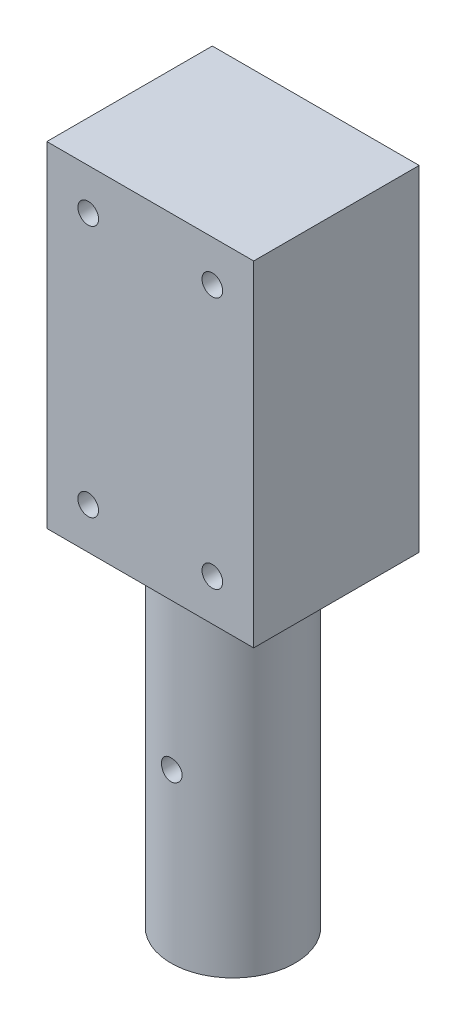
from build123d import *

# Parameters (mm, degrees)
SKETCH1_W             = 50
SKETCH1_H             = 40
BOSS_EXTRUDE1_DEPTH   = 81
SKETCH2_R             = 15
BOSS_EXTRUDE2_DEPTH   = 81
SKETCH3_R             = 2.5
CUT_EXTRUDE1_DEPTH    = 41
M6_TAPPED_HOLE1_D     = 5
M6_TAPPED_HOLE1_DEPTH = 13.497848452
M6_TAPPED_HOLE1_TIP   = 1.502151548
M6_TAPPED_HOLE4_D     = 5
M6_TAPPED_HOLE4_DEPTH = 13.497848452
M6_TAPPED_HOLE4_TIP   = 1.502151548


with BuildPart() as part:
    # Sketch1 → Boss-Extrude1 (new body)
    with BuildSketch(Plane(origin=(0, 0, 0), x_dir=(1, 0, 0), z_dir=(0, 1, 0))):
        with Locations((25, 20)):
            Rectangle(SKETCH1_W, SKETCH1_H)
    extrude(amount=BOSS_EXTRUDE1_DEPTH)

    # Sketch2 → Boss-Extrude2 (add)
    with BuildSketch(Plane.XZ):
        with Locations((25, -20)):
            Circle(SKETCH2_R)
    extrude(amount=BOSS_EXTRUDE2_DEPTH)

    # Sketch3 → Cut-Extrude1 (cut, through all)
    with BuildSketch(Plane.XY):
        with Locations((25, -40.5)):
            Circle(SKETCH3_R)
    extrude(amount=-CUT_EXTRUDE1_DEPTH, mode=Mode.SUBTRACT)

    # M6 Tapped Hole1
    with Locations(Plane.XY):
        with Locations((10, 10), (40, 10), (40, 71), (10, 71)):
            Hole(M6_TAPPED_HOLE1_D / 2, depth=M6_TAPPED_HOLE1_DEPTH)
            with Locations((0, 0, -(M6_TAPPED_HOLE1_DEPTH + M6_TAPPED_HOLE1_TIP / 2))):  # 118° drill point
                Cone(0, M6_TAPPED_HOLE1_D / 2, M6_TAPPED_HOLE1_TIP, mode=Mode.SUBTRACT)

    # M6 Tapped Hole4
    with Locations(Plane(origin=(50.277007324, 10.627759916, -40), x_dir=(-1, 0, 0), z_dir=(0, 0, -1))):
        with Locations((10.277007324, -0.627759916), (40.277007324, -0.627759916), (40.277007324, 60.372240084), (10.277007324, 60.372240084)):
            Hole(M6_TAPPED_HOLE4_D / 2, depth=M6_TAPPED_HOLE4_DEPTH)
            with Locations((0, 0, -(M6_TAPPED_HOLE4_DEPTH + M6_TAPPED_HOLE4_TIP / 2))):  # 118° drill point
                Cone(0, M6_TAPPED_HOLE4_D / 2, M6_TAPPED_HOLE4_TIP, mode=Mode.SUBTRACT)


solid = part.part
